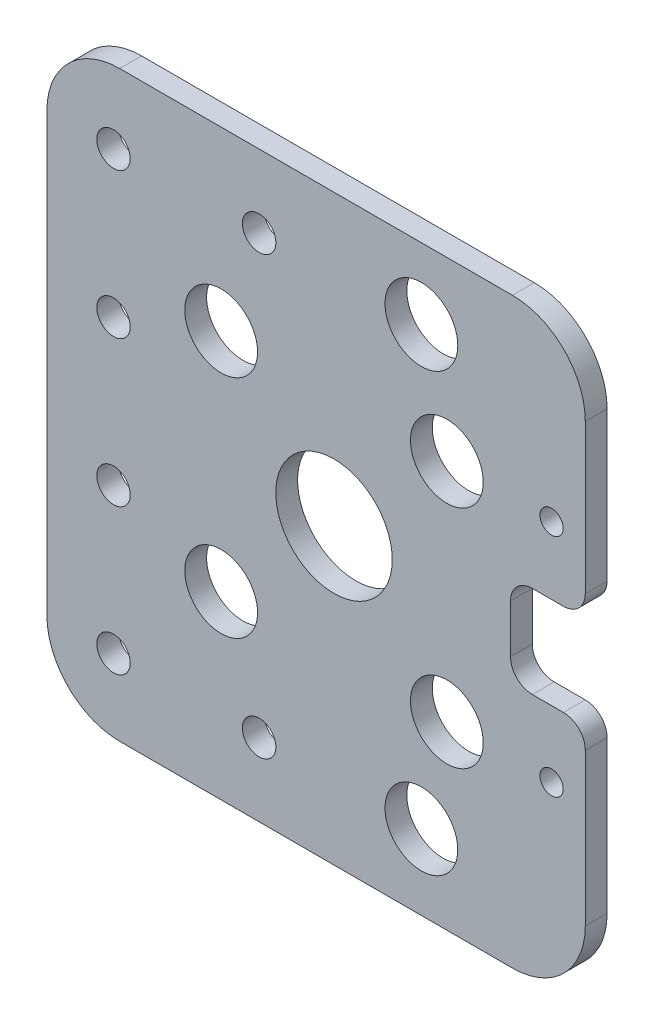
from build123d import *

# Parameters (mm, degrees)
SKETCH1_R           = 2.3
SKETCH1_R_2         = 5
SKETCH1_R_3         = 8
SKETCH1_R_4         = 1.6
BOSS_EXTRUDE1_DEPTH = 3
FILLET1_R           = 3


with BuildPart() as part:
    # Sketch1 → Boss-Extrude1 (new body)
    with BuildSketch(Plane.XY):
        with BuildLine():
            Line((157.960700719, -71.866196008), (170.473892307, -71.866196008))
            ThreePointArc((170.473892307, -71.866196008), (177.544960119, -74.795128196), (180.473892307, -81.866196008))
            Line((180.473892307, -81.866196008), (180.473892307, -102.365535019))
            Line((180.473892307, -102.365535019), (180.473892307, -105.365535019))
            Line((180.473892307, -105.365535019), (170.198907285, -105.365535019))
            Line((170.198907285, -105.365535019), (170.198907285, -117.989469864))
            Line((170.198907285, -117.989469864), (180.473892307, -117.989469864))
            Line((180.473892307, -117.989469864), (180.473892307, -120.989469864))
            Line((180.473892307, -120.989469864), (180.473892307, -141.896756479))
            ThreePointArc((180.473892307, -141.896756479), (177.544960119, -148.967824291), (170.473892307, -151.896756479))
            Line((170.473892307, -151.896756479), (157.960700719, -151.896756479))
            Line((157.960700719, -151.896756479), (116.525823666, -151.896756479))
            ThreePointArc((116.525823666, -151.896756479), (109.454755854, -148.967824291), (106.525823666, -141.896756479))
            Line((106.525823666, -141.896756479), (106.525823666, -81.866196008))
            ThreePointArc((106.525823666, -81.866196008), (109.454755854, -74.795128196), (116.525823666, -71.866196008))
            Line((116.525823666, -71.866196008), (157.960700719, -71.866196008))
        make_face()
        with Locations((115.674612816, -101.866196008)):
            Circle(SKETCH1_R, mode=Mode.SUBTRACT)
        with Locations((115.674612816, -121.866196008)):
            Circle(SKETCH1_R, mode=Mode.SUBTRACT)
        with Locations((135.674612816, -141.866196008)):
            Circle(SKETCH1_R, mode=Mode.SUBTRACT)
        with Locations((135.674612816, -81.866196008)):
            Circle(SKETCH1_R, mode=Mode.SUBTRACT)
        with Locations((115.674612816, -81.866196008)):
            Circle(SKETCH1_R, mode=Mode.SUBTRACT)
        with Locations((115.674612816, -141.866196008)):
            Circle(SKETCH1_R, mode=Mode.SUBTRACT)
        with Locations((161.460700719, -96.114221831)):
            Circle(SKETCH1_R_2, mode=Mode.SUBTRACT)
        with Locations((161.460700719, -127.114221831)):
            Circle(SKETCH1_R_2, mode=Mode.SUBTRACT)
        with Locations((130.460700719, -96.114221831)):
            Circle(SKETCH1_R_2, mode=Mode.SUBTRACT)
        with Locations((145.960700719, -111.591712302)):
            Circle(SKETCH1_R_3, mode=Mode.SUBTRACT)
        with Locations((175.843347401, -96.114221831)):
            Circle(SKETCH1_R_4, mode=Mode.SUBTRACT)
        with Locations((157.960700719, -81.591712302)):
            Circle(SKETCH1_R_2, mode=Mode.SUBTRACT)
        with Locations((157.960700719, -141.591712302)):
            Circle(SKETCH1_R_2, mode=Mode.SUBTRACT)
        with Locations((175.843347401, -127.114221831)):
            Circle(SKETCH1_R_4, mode=Mode.SUBTRACT)
        with Locations((130.460700719, -127.114221831)):
            Circle(SKETCH1_R_2, mode=Mode.SUBTRACT)
    extrude(amount=BOSS_EXTRUDE1_DEPTH)

    # Fillet1
    fillet1_edges = [part.edges().sort_by_distance(p)[0] for p in [
        (180.473892307, -105.365535019, 1.5),
        (170.198907285, -105.365535019, 1.5),
        (170.198907285, -117.989469864, 1.5),
        (180.473892307, -117.989469864, 1.5),
    ]]
    fillet(fillet1_edges, radius=FILLET1_R)


solid = part.part
